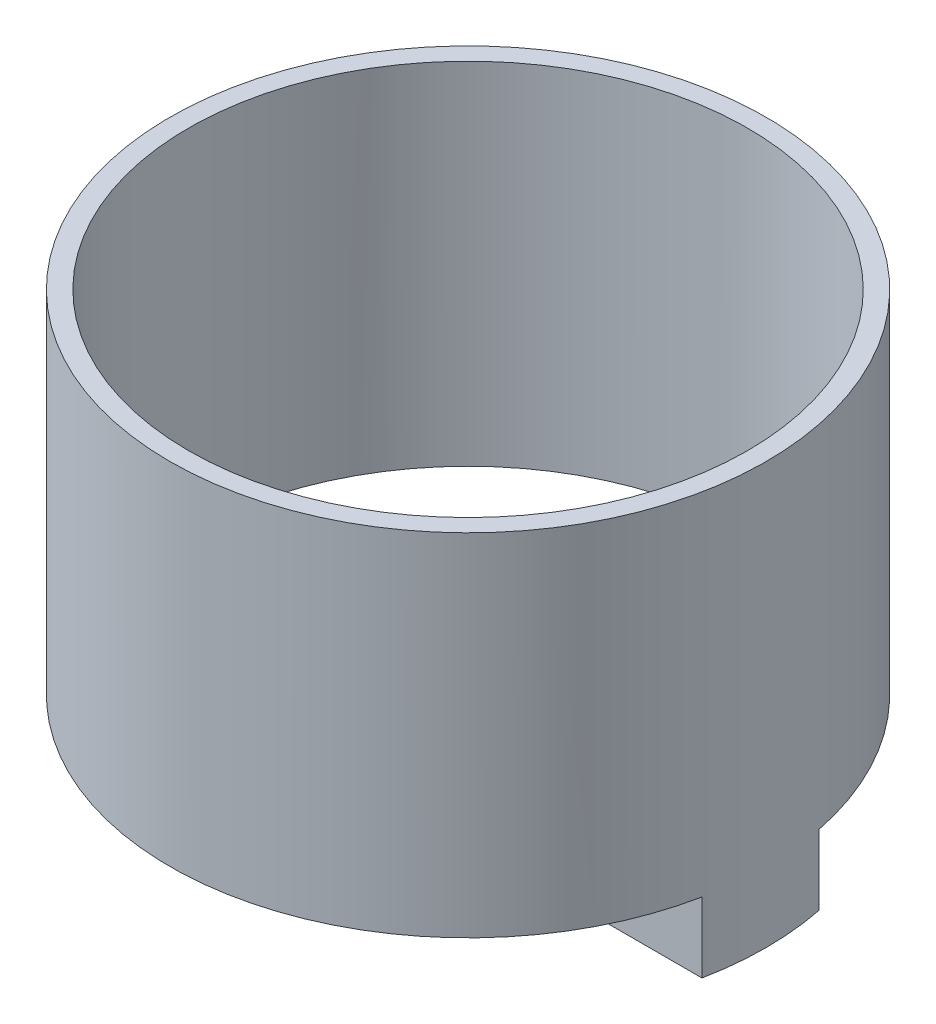
from build123d import *

# Parameters (mm, degrees)
SKETCH2_R           = 12.75
SKETCH2_R_2         = 11.95
BOSS_EXTRUDE1_DEPTH = 15
BOSS_EXTRUDE2_DEPTH = 3


with BuildPart() as part:
    # Sketch2 → Boss-Extrude1 (new body)
    with BuildSketch(Plane(origin=(0, 0, 0), x_dir=(1, 0, 0), z_dir=(0, 1, 0))):
        Circle(SKETCH2_R)
        Circle(SKETCH2_R_2, mode=Mode.SUBTRACT)
    extrude(amount=BOSS_EXTRUDE1_DEPTH)

    # Sketch3 → Boss-Extrude2 (add)
    with BuildSketch(Plane.XZ):
        with BuildLine():
            Line((5.25, -2.5), (5.25, 2.5))
            Line((5.25, 2.5), (12.5025, 2.5))
            ThreePointArc((12.5025, 2.5), (12.75, 0), (12.5025, -2.5))
            Line((12.5025, -2.5), (5.25, -2.5))
        make_face()
        with BuildLine():
            Line((-5.25, -2.5), (-12.5025, -2.5))
            ThreePointArc((-12.5025, -2.5), (-12.75, 0), (-12.5025, 2.5))
            Line((-12.5025, 2.5), (-5.25, 2.5))
            Line((-5.25, 2.5), (-5.25, -2.5))
        make_face()
    extrude(amount=BOSS_EXTRUDE2_DEPTH)


solid = part.part
